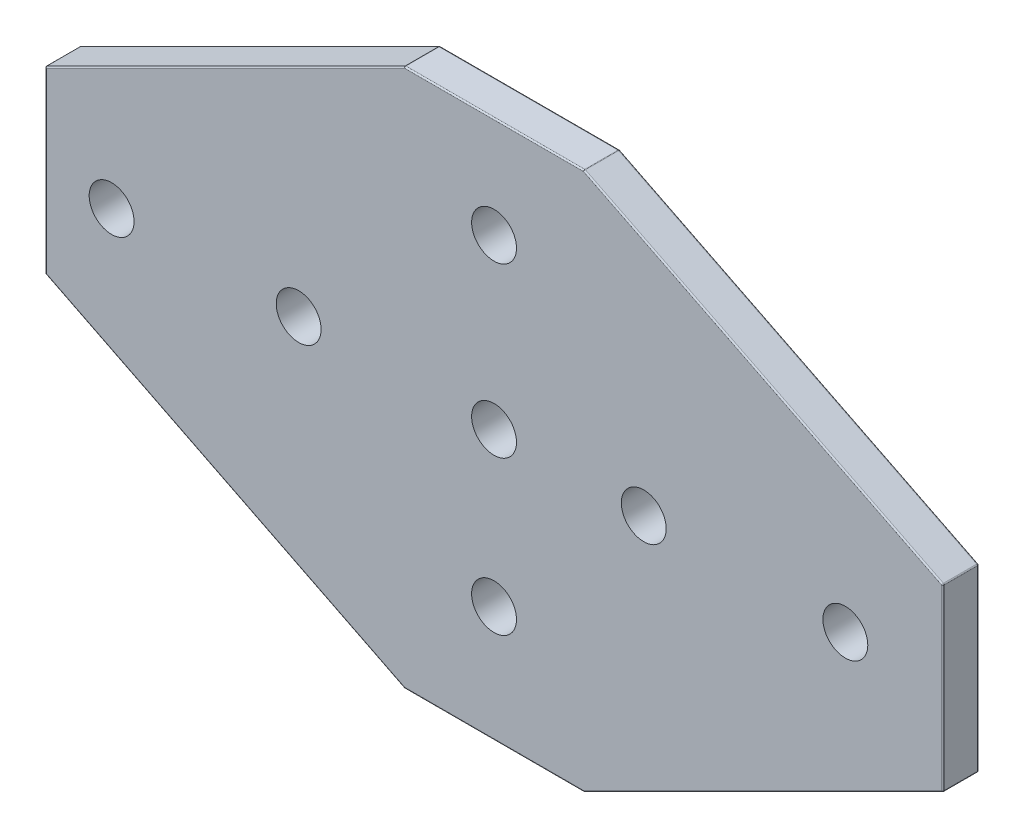
from build123d import *

# Parameters (mm, degrees)
BOSS_EXTRUDE2_DEPTH = 4
SKETCH4_OUTSIDE_W   = 125.338
SKETCH4_OUTSIDE_H   = 85.338
SKETCH4_OUTSIDE_R   = 2.5
CUT_EXTRUDE4_DEPTH  = 4
FILLET1_R           = 0.15


with BuildPart() as part:
    # Sketch1 → Boss-Extrude2 (new body)
    with BuildSketch(Plane.XY):
        Polygon((-50, 10), (-50, -10), (-10, -30), (10, -30), (50, -10), (50, 10), (10, 30), (-10, 30), align=None)
    extrude(amount=BOSS_EXTRUDE2_DEPTH)

    # Sketch4 outside → Cut-Extrude4 (cut)
    with BuildSketch(Plane.XY.offset(4)):
        Rectangle(SKETCH4_OUTSIDE_W, SKETCH4_OUTSIDE_H)
        Polygon((-10, 30), (-50, 10), (-50, -10), (-10, -30), (10, -30), (50, -10), (50, 10), (10, 30), align=None, mode=Mode.SUBTRACT)
        Circle(SKETCH4_OUTSIDE_R)
        with Locations((-21.764530358, 0)):
            Circle(SKETCH4_OUTSIDE_R)
        with Locations((-42.602849817, 0)):
            Circle(SKETCH4_OUTSIDE_R)
        with Locations((16.676409958, 0)):
            Circle(SKETCH4_OUTSIDE_R)
        with Locations((39.134669841, 0)):
            Circle(SKETCH4_OUTSIDE_R)
        with Locations((0, 18.729540895)):
            Circle(SKETCH4_OUTSIDE_R)
        with Locations((0, -17.102871632)):
            Circle(SKETCH4_OUTSIDE_R)
    extrude(amount=-CUT_EXTRUDE4_DEPTH, mode=Mode.SUBTRACT)

    # Fillet1
    fillet1_edges = [part.edges().sort_by_distance(p)[0] for p in [
        (-30, -20, 4),
        (-50, 0, 0),
        (-30, 20, 0),
        (0, -30, 4),
        (-10, 30, 2),
        (10, 30, 2),
        (50, 10, 2),
        (50, -10, 2),
        (10, -30, 2),
        (-10, -30, 2),
        (-50, -10, 2),
        (-50, 10, 2),
        (30, -20, 4),
        (50, 0, 4),
        (30, 20, 4),
        (0, 30, 4),
        (-30, 20, 4),
        (-50, 0, 4),
        (0, 30, 0),
        (30, 20, 0),
        (50, 0, 0),
        (30, -20, 0),
        (0, -30, 0),
        (-30, -20, 0),
    ]]
    fillet(fillet1_edges, radius=FILLET1_R)


solid = part.part
